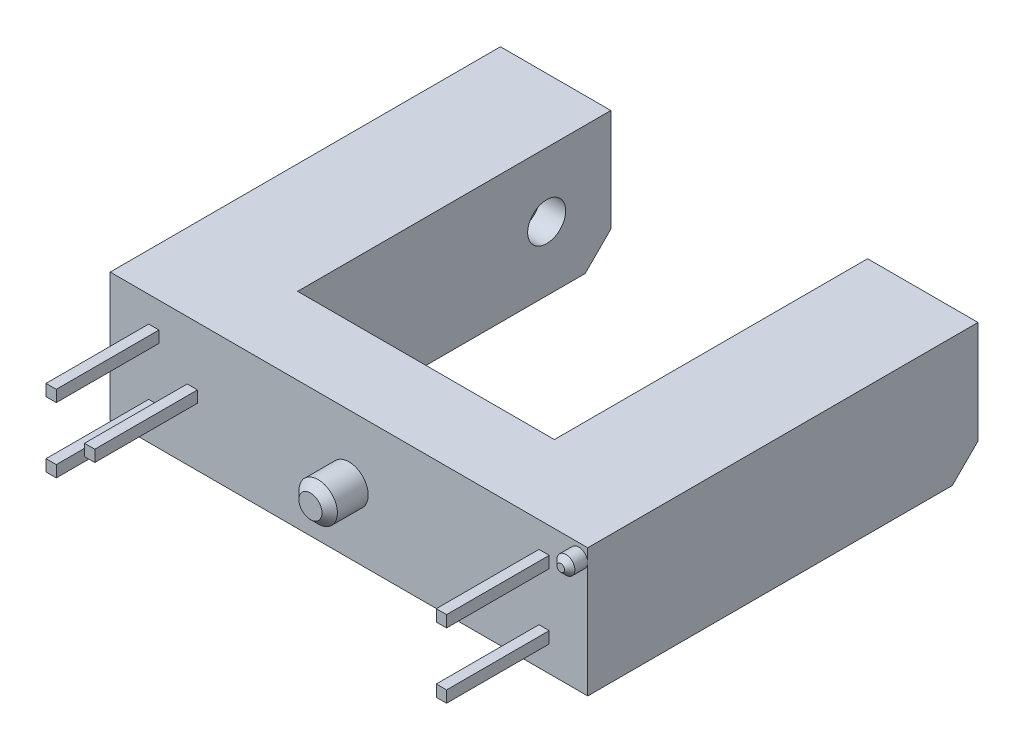
from build123d import *

# Parameters (mm, degrees)
BOSS_EXTRUDE1_DEPTH = 2.5
SKETCH3_R           = 0.75
BOSS_EXTRUDE2_DEPTH = 1.5
SKETCH4_R           = 0.35
BOSS_EXTRUDE3_DEPTH = 0.7
CHAMFER1_SIZE       = 0.2
CHAMFER2_SIZE       = 0.3
CHAMFER3_SIZE       = 1
SKETCH5_W           = 0.4
SKETCH5_H           = 0.45
BOSS_EXTRUDE4_DEPTH = 4
SKETCH6_R           = 0.740287865
CUT_EXTRUDE1_DEPTH  = 1


with BuildPart() as part:
    # Sketch1 → Boss-Extrude1 (new body, symmetric)
    with BuildSketch(Plane(origin=(0, 0, 0), x_dir=(1, 0, 0), z_dir=(0, 1, 0))):
        Polygon((5, 2.5), (9.3, 2.5), (9.3, -12.7), (-9.3, -12.7), (-9.3, 2.5), (-5, 2.5), (-5, -9.7), (5, -9.7), align=None)
    extrude(amount=BOSS_EXTRUDE1_DEPTH, both=True)

    # Sketch3 → Boss-Extrude2 (add)
    with BuildSketch(Plane.XY.offset(12.7)):
        Circle(SKETCH3_R)
    extrude(amount=BOSS_EXTRUDE2_DEPTH)

    # Sketch4 → Boss-Extrude3 (add)
    with BuildSketch(Plane.XY.offset(12.7)):
        with Locations((8.95, 2)):
            Circle(SKETCH4_R)
    extrude(amount=BOSS_EXTRUDE3_DEPTH)

    # Chamfer1
    chamfer1_edges = [part.edges().sort_by_distance(p)[0] for p in [
        (8.6, 2, 13.4),
    ]]
    chamfer(chamfer1_edges, length=CHAMFER1_SIZE)

    # Chamfer2
    chamfer2_edges = [part.edges().sort_by_distance(p)[0] for p in [
        (-0.75, 0, 14.2),
    ]]
    chamfer(chamfer2_edges, length=CHAMFER2_SIZE)

    # Chamfer3
    chamfer3_edges = [part.edges().sort_by_distance(p)[0] for p in [
        (-7.15, -2.5, -2.5),
        (7.15, -2.5, -2.5),
    ]]
    chamfer(chamfer3_edges, length=CHAMFER3_SIZE)

    # Sketch5 → Boss-Extrude4 (add)
    with BuildSketch(Plane.XY.offset(12.7)):
        with Locations((-7.6, 1.27)):
            Rectangle(SKETCH5_W, SKETCH5_H)
        with Locations((-7.6, -1.27)):
            Rectangle(SKETCH5_W, SKETCH5_H)
        with Locations((-6.1, 0)):
            Rectangle(SKETCH5_W, SKETCH5_H)
        with Locations((7.6, 1.27)):
            Rectangle(SKETCH5_W, SKETCH5_H)
        with Locations((7.6, -1.27)):
            Rectangle(SKETCH5_W, SKETCH5_H)
    extrude(amount=BOSS_EXTRUDE4_DEPTH)

    # Sketch6 → Cut-Extrude1 (cut)
    with BuildSketch(Plane(origin=(-5, 0, 0), x_dir=(0, 0, -1), z_dir=(1, 0, 0))):
        Circle(SKETCH6_R)
    extrude(amount=-CUT_EXTRUDE1_DEPTH, mode=Mode.SUBTRACT)


solid = part.part
